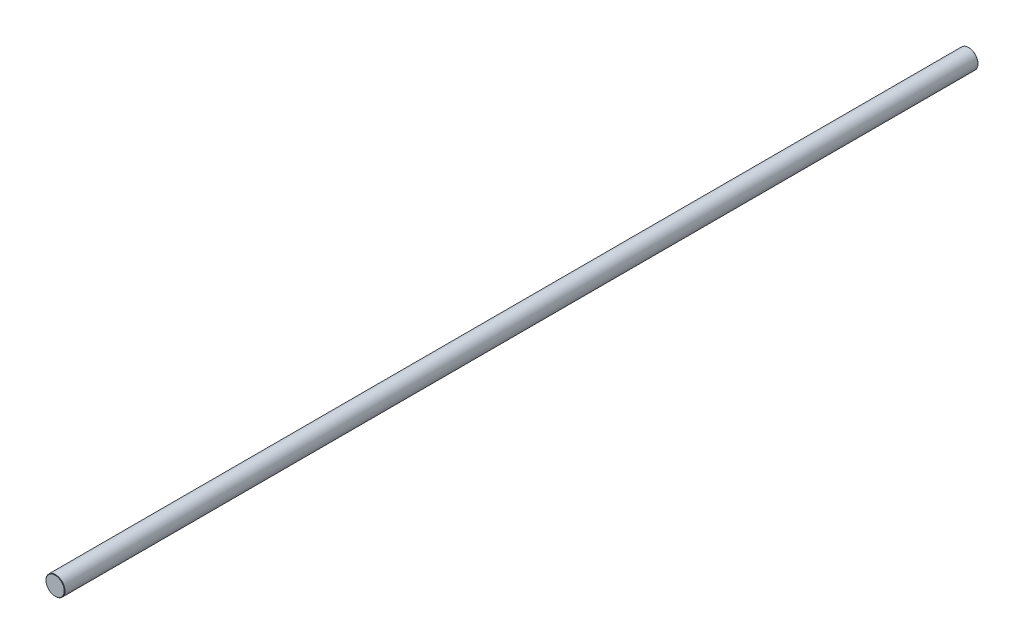
from build123d import *

# Parameters (mm, degrees)
SKETCH3_R                = 12.5
BOSS_EXTRUDE1_DEPTH      = 600
BOSS_EXTRUDE1_DEPTH_BACK = 600
CHAMFER1_SIZE            = 0.5


with BuildPart() as part:
    # Sketch3 → Boss-Extrude1 (new body, two sides)
    with BuildSketch(Plane.XY) as boss_extrude1_sk:
        Circle(SKETCH3_R)
    extrude(amount=BOSS_EXTRUDE1_DEPTH)
    extrude(boss_extrude1_sk.sketch, amount=-BOSS_EXTRUDE1_DEPTH_BACK)

    # Chamfer1
    chamfer1_edges = [part.edges().sort_by_distance(p)[0] for p in [
        (-12.5, 0, -600),
        (-12.5, 0, 600),
    ]]
    chamfer(chamfer1_edges, length=CHAMFER1_SIZE)


solid = part.part
